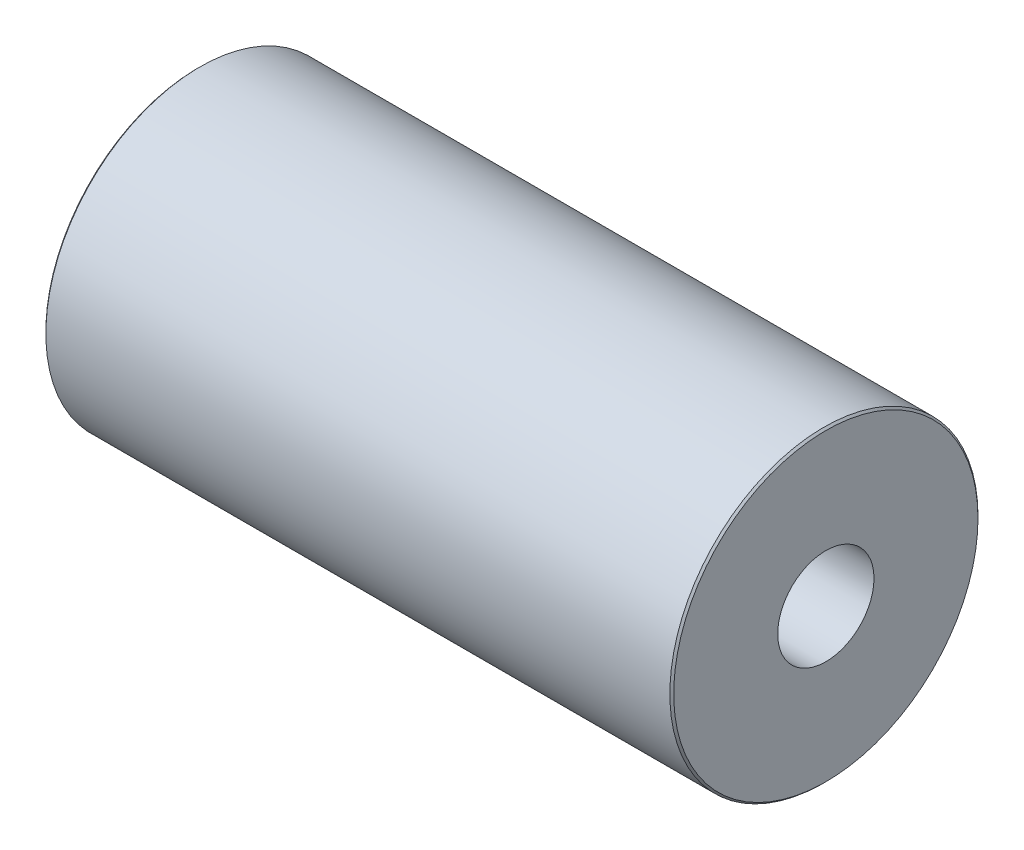
from build123d import *

# Parameters (mm, degrees)
SKETCH1_R           = 8
SKETCH1_R_2         = 3
BOSS_EXTRUDE1_DEPTH = 16.3
CHAMFER1_SIZE       = 0.1


with BuildPart() as part:
    # Sketch1 → Boss-Extrude1 (new, symmetric)
    with BuildSketch(Plane(origin=(0, 0, 0), x_dir=(0, 0, -1), z_dir=(1, 0, 0))):
        Circle(SKETCH1_R)
        Circle(SKETCH1_R_2, mode=Mode.SUBTRACT)
        Circle(SKETCH1_R_2)
    extrude(amount=BOSS_EXTRUDE1_DEPTH, both=True)

    # Sketch3 → M6 Tapped Hole1 (revolve, cut)
    with BuildSketch(Plane(origin=(-16.3, 0, 0), x_dir=(0, 0, 1), z_dir=(0, 1, 0))):
        Polygon((0, 0), (0, 11.502151548), (2.5, 10), (2.5, 0), align=None)
    m6_tapped_hole1 = revolve(axis=Axis((-22.65, 0, 0), (1, 0, 0)), mode=Mode.SUBTRACT)

    # Mirror1: M6 Tapped Hole1 across plane
    add(m6_tapped_hole1.mirror(Plane(origin=(0, 0, 0), x_dir=(0, 0, 1), z_dir=(1, 0, 0))), mode=Mode.SUBTRACT)

    # Chamfer1
    chamfer1_edges = [part.edges().sort_by_distance(p)[0] for p in [
        (-16.3, 0, 8),
        (16.3, 0, 8),
    ]]
    chamfer(chamfer1_edges, length=CHAMFER1_SIZE)


solid = part.part
